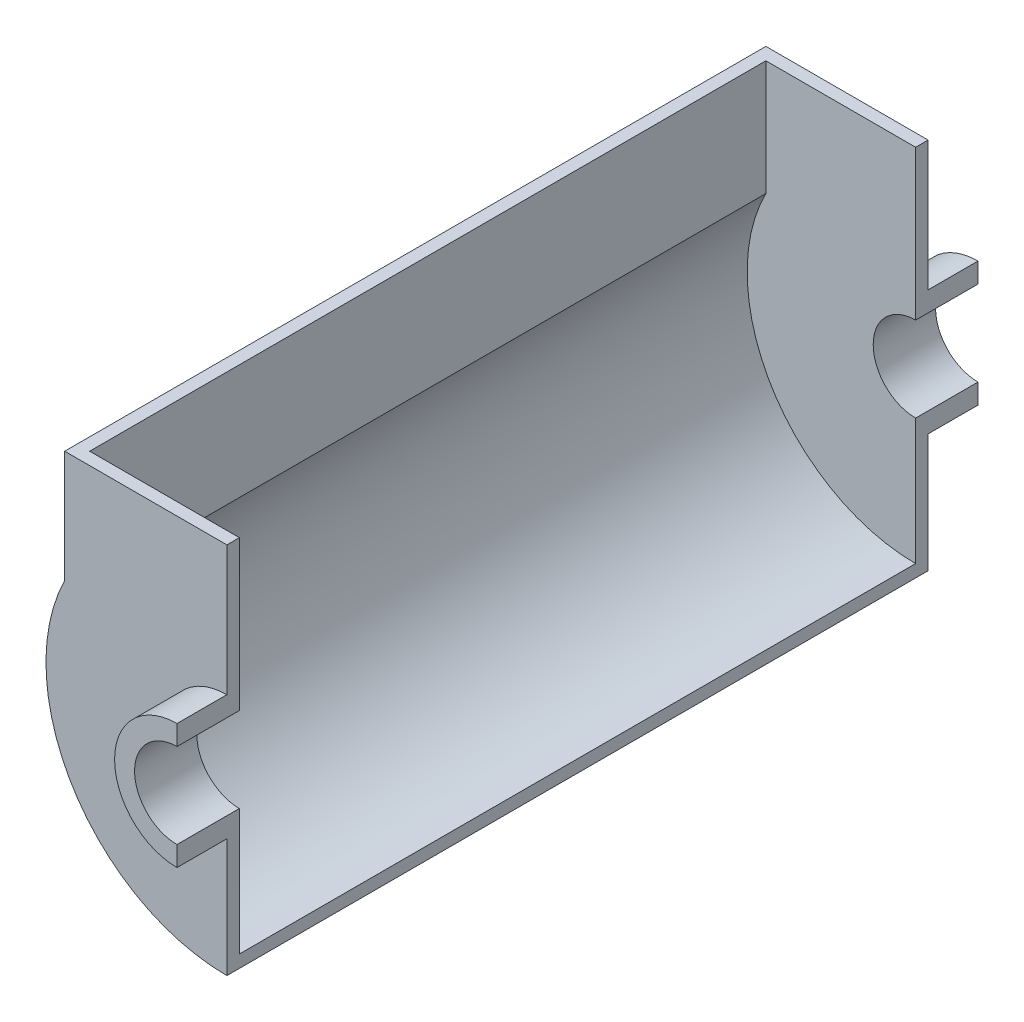
from build123d import *

# Parameters (mm, degrees)
BOSS_EXTRUDE1_DEPTH      = 508
BOSS_EXTRUDE1_DEPTH_BACK = 127
BOSS_EXTRUDE2_DEPTH      = 127
BOSS_EXTRUDE3_DEPTH      = 6883.4


with BuildPart() as part:
    # Sketch1 → Boss-Extrude1 (new body, two sides)
    with BuildSketch(Plane.XY) as boss_extrude1_sk:
        with BuildLine():
            Line((0, 635), (0, 431.8))
            ThreePointArc((0, 431.8), (-431.8, 0), (0, -431.8))
            Line((0, -431.8), (0, -635))
            ThreePointArc((0, -635), (-635, 0), (0, 635))
        make_face()
    extrude(amount=BOSS_EXTRUDE1_DEPTH)
    extrude(boss_extrude1_sk.sketch, amount=-BOSS_EXTRUDE1_DEPTH_BACK)

    # Sketch2 → Boss-Extrude2 (add)
    with BuildSketch(Plane.XY):
        with BuildLine():
            Line((0, 635), (0, 1955.8))
            Line((0, 1955.8), (-1651, 1955.8))
            Line((-1651, 1955.8), (-1651, 815.672268745))
            ThreePointArc((-1651, 815.672268745), (-1564.158357216, -971.869787344), (0, -1841.5))
            Line((0, -1841.5), (0, -635))
            ThreePointArc((0, -635), (-635, 0), (0, 635))
        make_face()
    extrude(amount=-BOSS_EXTRUDE2_DEPTH)


with BuildPart() as body_2:
    # Mirror1: mirrored copy
    add(part.part.mirror(Plane.XY.offset(-3568.7)))


with BuildPart() as part_1:
    add(part.part)

    add(body_2.part)  # Boss-Extrude3 merges body 2
    # Sketch3 → Boss-Extrude3 (add)
    with BuildSketch(Plane(origin=(0, 0, -127), x_dir=(-1, 0, 0), z_dir=(0, 0, -1))):
        with BuildLine():
            Line((1651, 1955.8), (1651, 815.672268745))
            ThreePointArc((1651, 815.672268745), (1564.158357216, -971.869787344), (0, -1841.5))
            Line((0, -1841.5), (0, -1714.5))
            ThreePointArc((0, -1714.5), (1463.92743252, -892.42743252), (1524, 785.45162168))
            Line((1524, 785.45162168), (1524, 1955.8))
            Line((1524, 1955.8), (1651, 1955.8))
        make_face()
    extrude(amount=BOSS_EXTRUDE3_DEPTH)


solid = part_1.part
